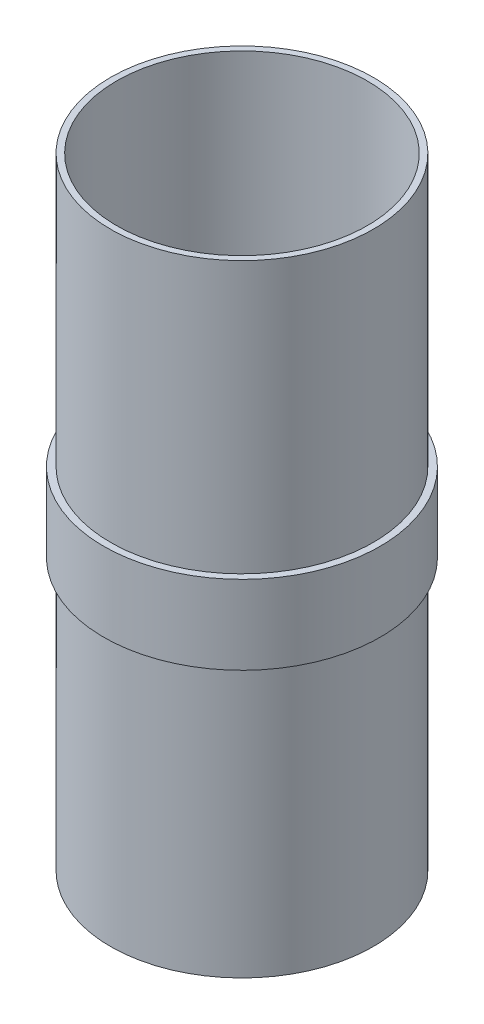
from build123d import *


with BuildPart() as part:
    # Sketch1 → Revolve1 (revolve)
    with BuildSketch(Plane.XY):
        Polygon((0, 0), (0, 233.3625), (-2.286, 233.3625), (-2.286, 131.47675), (-4.826, 131.47675), (-4.826, 101.88575), (-2.286, 101.88575), (-2.286, 0), align=None)
    revolve(axis=Axis((47.1043, 199.644, 0), (0, -1, 0)))


solid = part.part
